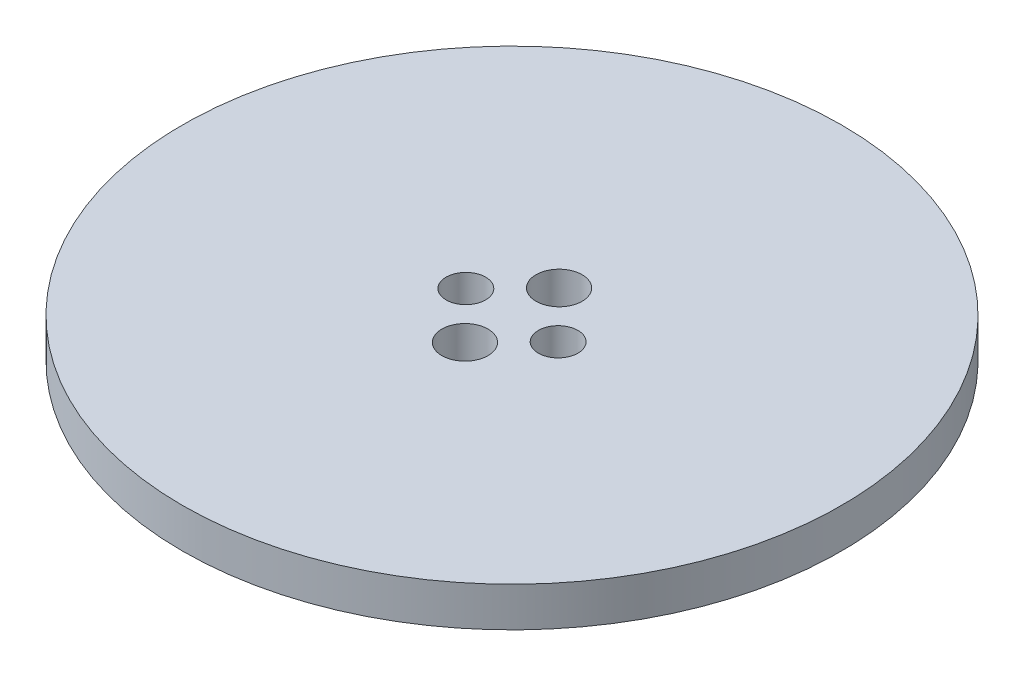
from build123d import *

# Parameters (mm, degrees)
ESQUISSE1_R        = 25
ESQUISSE1_R_2      = 1.5
ESQUISSE1_R_3      = 1.75
BOSS_EXTRU_1_DEPTH = 3


with BuildPart() as part:
    # Esquisse1 → Boss.-Extru.1 (new body)
    with BuildSketch(Plane(origin=(0, 0, 0), x_dir=(1, 0, 0), z_dir=(0, 1, 0))):
        Circle(ESQUISSE1_R)
        with Locations((-3.5, 0)):
            Circle(ESQUISSE1_R_2, mode=Mode.SUBTRACT)
        with Locations((3.5, 0)):
            Circle(ESQUISSE1_R_2, mode=Mode.SUBTRACT)
        with Locations((0, 3.570714214)):
            Circle(ESQUISSE1_R_3, mode=Mode.SUBTRACT)
        with Locations((0, -3.570714214)):
            Circle(ESQUISSE1_R_3, mode=Mode.SUBTRACT)
    extrude(amount=BOSS_EXTRU_1_DEPTH)


solid = part.part
